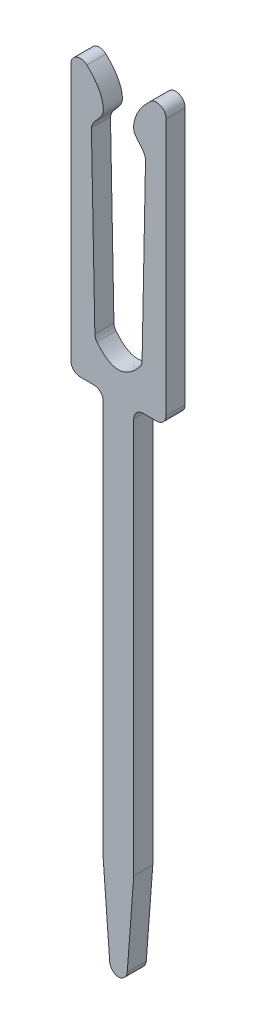
from build123d import *

# Parameters (mm, degrees)
BOSS_EXTRUDE1_DEPTH = 0.2


with BuildPart() as part:
    # Sketch1 → Boss-Extrude1 (new body, symmetric)
    with BuildSketch(Plane.XY):
        with BuildLine():
            Line((-0.32, 1.999393664), (-0.32, 10.299393664))
            ThreePointArc((-0.32, 10.299393664), (-0.378578644, 10.44081502), (-0.52, 10.499393664))
            Line((-0.52, 10.499393664), (-0.8, 10.499393664))
            ThreePointArc((-0.8, 10.499393664), (-0.941421356, 10.557972308), (-1, 10.699393664))
            Line((-1, 10.699393664), (-1, 16.089817201))
            ThreePointArc((-1, 16.089817201), (-0.87939743, 16.273382034), (-0.663039519, 16.235562961))
            add(Edge.make_bspline(
                [(-0.663039519, 16.235562961), (-0.487599251, 16.070697902), (-0.326177604, 15.848773555), (-0.310671132, 15.420865905), (-0.548453888, 15.308603212), (-0.567669208, 15.140963485)],
                knots=[0.253308427, 0.253308427, 0.253308427, 0.253308427, 0.663171976, 0.707067436, 1, 1, 1, 1], degree=3))
            Line((-0.567669208, 15.140963485), (-0.495215905, 11.434303234))
            ThreePointArc((-0.495215905, 11.434303234), (-0.483221967, 11.369888483), (-0.451053839, 11.312806733))
            add(Edge.make_bspline(
                [(-0.451053839, 11.312806733), (0, 10.752430299), (0.451053839, 11.312806733)],
                knots=[0.043404734, 0.043404734, 0.043404734, 0.956595266, 0.956595266, 0.956595266], degree=2))
            ThreePointArc((0.451053839, 11.312806733), (0.483221967, 11.369888483), (0.495215905, 11.434303234))
            Line((0.495215905, 11.434303234), (0.567669208, 15.140963485))
            add(Edge.make_bspline(
                [(0.663039519, 16.235562961), (0.487599251, 16.070697902), (0.326177604, 15.848773555), (0.310671132, 15.420865905), (0.548453888, 15.308603212), (0.567669208, 15.140963485)],
                knots=[0.253308427, 0.253308427, 0.253308427, 0.253308427, 0.663171976, 0.707067436, 1, 1, 1, 1], degree=3))
            ThreePointArc((0.663039519, 16.235562961), (0.87939743, 16.273382034), (1, 16.089817201))
            Line((1, 16.089817201), (1, 10.699393664))
            ThreePointArc((1, 10.699393664), (0.941421356, 10.557972308), (0.8, 10.499393664))
            Line((0.8, 10.499393664), (0.52, 10.499393664))
            ThreePointArc((0.52, 10.499393664), (0.378578644, 10.44081502), (0.32, 10.299393664))
            Line((0.32, 10.299393664), (0.32, 1.999393664))
            Line((0.32, 1.999393664), (0.183878151, 0.184435674))
            ThreePointArc((0.183878151, 0.184435674), (0.126073555, 0.058186541), (0, 0))
            ThreePointArc((0, 0), (-0.126073555, 0.058186541), (-0.183878151, 0.184435674))
            Line((-0.183878151, 0.184435674), (-0.32, 1.999393664))
        make_face()
    extrude(amount=BOSS_EXTRUDE1_DEPTH, both=True)


solid = part.part
